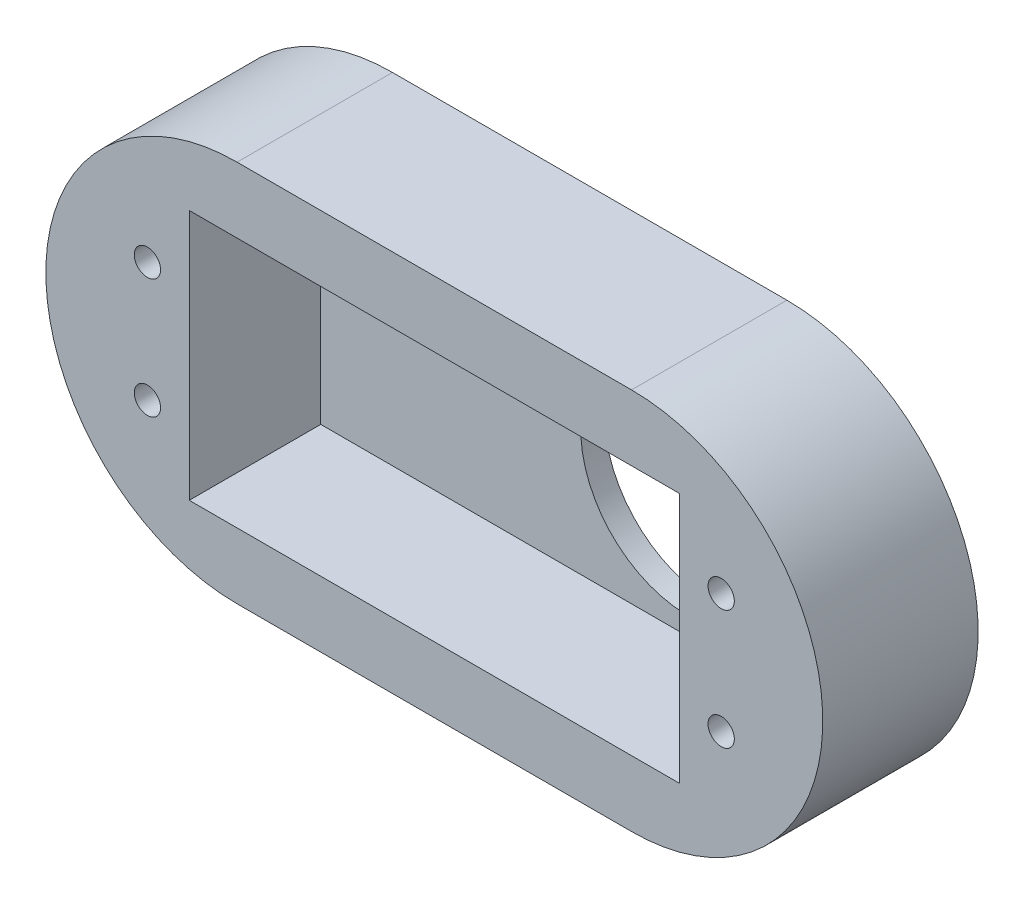
from build123d import *

# Parameters (mm, degrees)
SKETCH1_R           = 1.1
SKETCH1_W           = 41
SKETCH1_H           = 21
BOSS_EXTRUDE1_DEPTH = 11
SKETCH2_R           = 9.000000034
BOSS_EXTRUDE2_DEPTH = 2


with BuildPart() as part:
    # Sketch1 → Boss-Extrude1 (new body)
    with BuildSketch(Plane.XY):
        with BuildLine():
            Line((4, -5.500000004), (37, -5.500000004))
            ThreePointArc((37, -5.500000004), (53.000000004, 10.5), (37, 26.500000004))
            Line((37, 26.500000004), (4, 26.500000004))
            ThreePointArc((4, 26.500000004), (-12.000000004, 10.5), (4, -5.500000004))
        make_face()
        with Locations((-3.5, 15.5)):
            Circle(SKETCH1_R, mode=Mode.SUBTRACT)
        with Locations((-3.5, 5.5)):
            Circle(SKETCH1_R, mode=Mode.SUBTRACT)
        with Locations((44.5, 5.5)):
            Circle(SKETCH1_R, mode=Mode.SUBTRACT)
        with Locations((44.5, 15.5)):
            Circle(SKETCH1_R, mode=Mode.SUBTRACT)
        with Locations((20.5, 10.5)):
            Rectangle(SKETCH1_W, SKETCH1_H, mode=Mode.SUBTRACT)
    extrude(amount=BOSS_EXTRUDE1_DEPTH)

    # Sketch2 → Boss-Extrude2 (add)
    with BuildSketch(Plane.XY):
        with BuildLine():
            Line((37, 26.500000004), (4, 26.500000004))
            ThreePointArc((4, 26.500000004), (-12.000000004, 10.5), (4, -5.500000004))
            Line((4, -5.500000004), (37, -5.500000004))
            ThreePointArc((37, -5.500000004), (53.000000004, 10.5), (37, 26.500000004))
        make_face()
        with Locations((30.749999966, 10.5)):
            Circle(SKETCH2_R, mode=Mode.SUBTRACT)
    extrude(amount=-BOSS_EXTRUDE2_DEPTH)


solid = part.part
